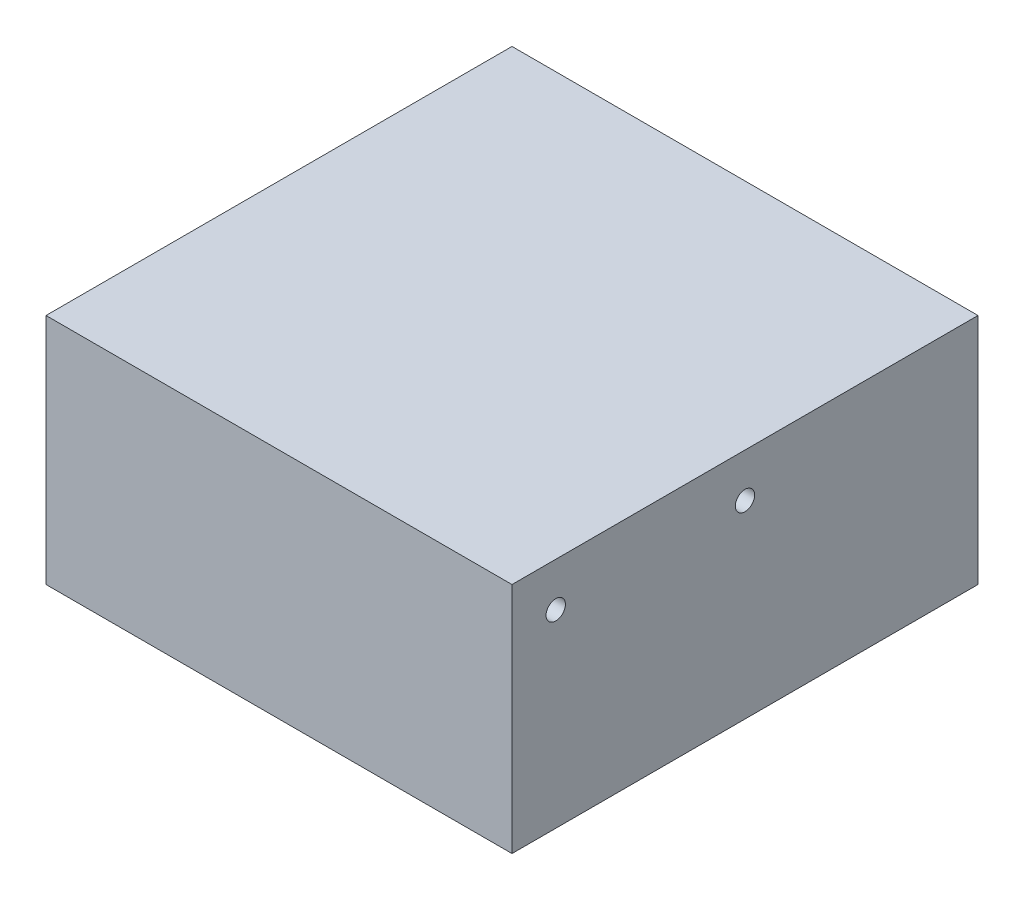
from build123d import *

# Parameters (mm, degrees)
SKETCH1_W               = 172
SKETCH1_H               = 172
BOSS_EXTRUDE1_DEPTH     = 86
SKETCH3_R               = 3.5687
CUT_EXTRUDE1_DEPTH      = 87
CUT_EXTRUDE1_DEPTH_BACK = 87


with BuildPart() as part:
    # Sketch1 → Boss-Extrude1 (new body)
    with BuildSketch(Plane(origin=(0, 0, 0), x_dir=(1, 0, 0), z_dir=(0, 1, 0))):
        Rectangle(SKETCH1_W, SKETCH1_H)
    extrude(amount=BOSS_EXTRUDE1_DEPTH)

    # Sketch2 → Cut-Revolve1 (revolve, cut)
    with BuildSketch(Plane.XY):
        with BuildLine():
            Line((0, 35), (0, 0))
            Line((0, 0), (35, 0))
            ThreePointArc((35, 0), (24.748737342, 24.748737342), (0, 35))
        make_face()
    revolve(axis=Axis((0, 35, 0), (0, -1, 0)), mode=Mode.SUBTRACT)

    # Sketch3 → Cut-Extrude1 (cut, two sides)
    with BuildSketch(Plane(origin=(0, 0, 0), x_dir=(0, 0, -1), z_dir=(1, 0, 0))) as cut_extrude1_sk:
        with Locations((-69.85, 69.85)):
            Circle(SKETCH3_R)
        with Locations((0, 69.85)):
            Circle(SKETCH3_R)
    extrude(amount=CUT_EXTRUDE1_DEPTH, mode=Mode.SUBTRACT)
    extrude(cut_extrude1_sk.sketch, amount=-CUT_EXTRUDE1_DEPTH_BACK, mode=Mode.SUBTRACT)


solid = part.part
